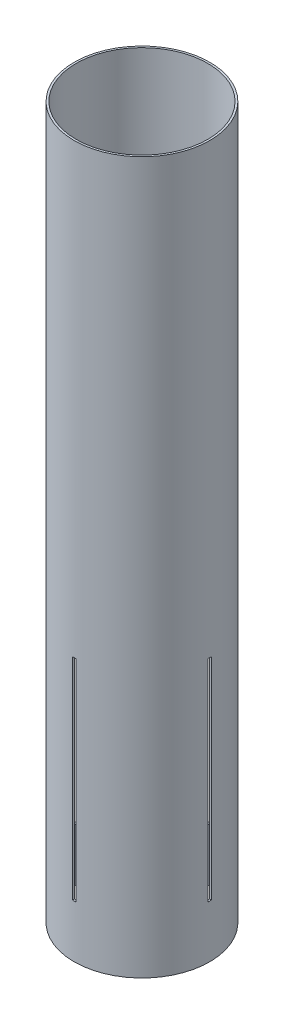
from build123d import *

# Parameters (mm, degrees)
SKETCH1_R           = 65.405
SKETCH1_R_2         = 63.5
BOSS_EXTRUDE1_DEPTH = 342.9
SKETCH4_W           = 3.175
SKETCH4_H           = 203.2
CUT_EXTRUDE2_DEPTH  = 66.405
CIRPATTERN4_COUNT   = 2
CIRPATTERN4_ANGLE   = 90


with BuildPart() as part:
    # Sketch1 → Boss-Extrude1 (new body, symmetric)
    with BuildSketch(Plane(origin=(0, 0, 0), x_dir=(1, 0, 0), z_dir=(0, 1, 0))):
        Circle(SKETCH1_R)
        Circle(SKETCH1_R_2, mode=Mode.SUBTRACT)
    extrude(amount=BOSS_EXTRUDE1_DEPTH, both=True)

    # Sketch4 → Cut-Extrude2 (cut, symmetric)
    with BuildSketch(Plane(origin=(0, 0, 0), x_dir=(0, 0, -1), z_dir=(1, 0, 0))):
        with Locations((0, -190.5)):
            Rectangle(SKETCH4_W, SKETCH4_H)
    cut_extrude2 = extrude(amount=CUT_EXTRUDE2_DEPTH, both=True, mode=Mode.SUBTRACT)

    # CirPattern4: Cut-Extrude2 ×2 about axis
    cirpattern4_axis = Axis((0, 342.9, 0), (0, -1, 0))
    for i in range(1, CIRPATTERN4_COUNT):
        add(cut_extrude2.rotate(cirpattern4_axis, i * CIRPATTERN4_ANGLE / (CIRPATTERN4_COUNT - 1)), mode=Mode.SUBTRACT)


solid = part.part
